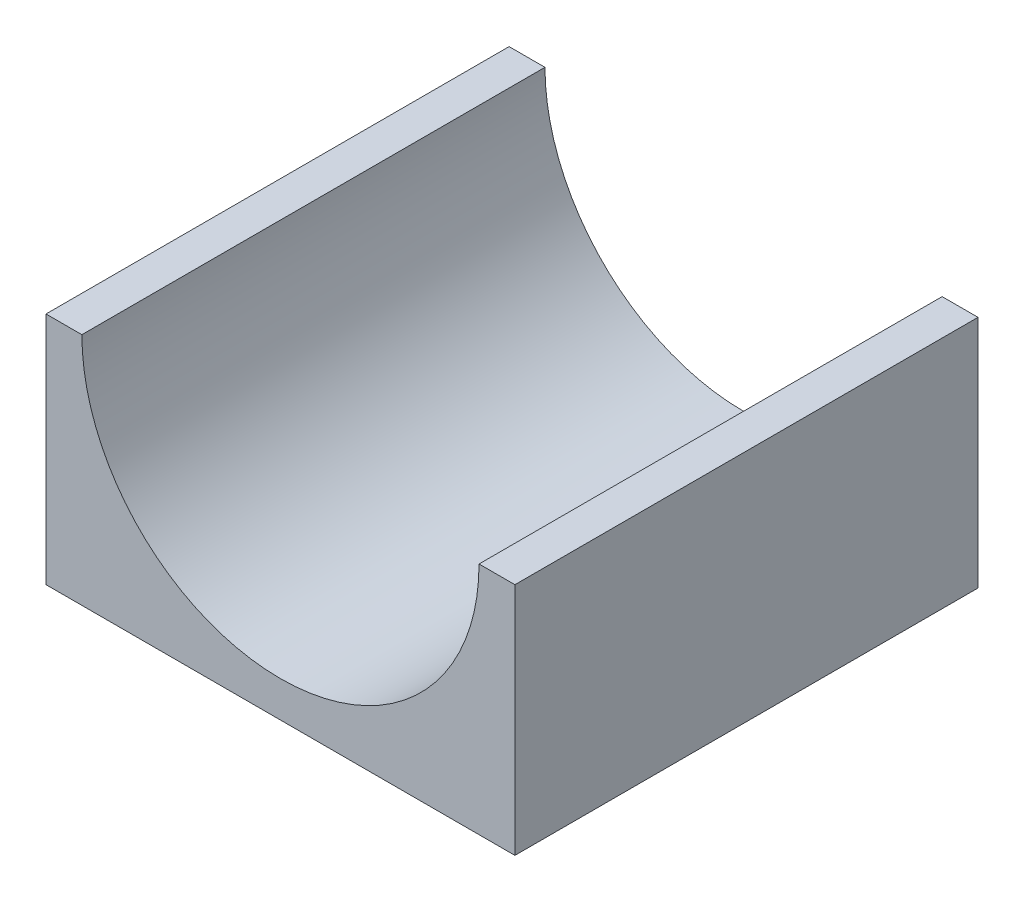
from build123d import *

# Parameters (mm, degrees)
BOSS_EXTRUDE1_DEPTH = 129.12


with BuildPart() as part:
    # Sketch1 → Boss-Extrude1 (new body)
    with BuildSketch(Plane.XY):
        with BuildLine():
            Line((0, 0), (0, 65.37))
            Line((0, 65.37), (10, 65.37))
            ThreePointArc((10, 65.37), (65.37, 10), (120.74, 65.37))
            Line((120.74, 65.37), (130.74, 65.37))
            Line((130.74, 65.37), (130.74, 0))
            Line((130.74, 0), (0, 0))
        make_face()
    extrude(amount=BOSS_EXTRUDE1_DEPTH)


solid = part.part
